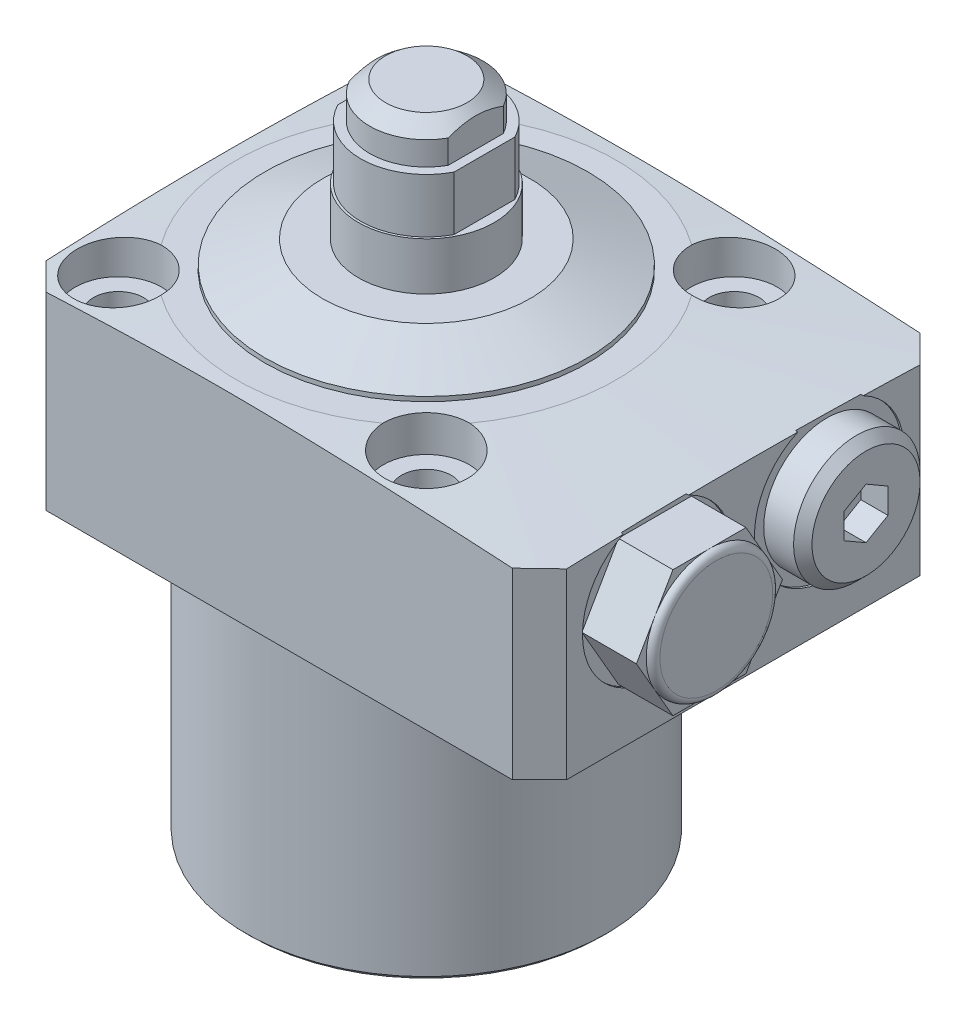
from build123d import *

# Parameters (mm, degrees)
SKETCH2_OUTSIDE_W          = 132.276
SKETCH2_OUTSIDE_H          = 132.276
SKETCH2_OUTSIDE_W_2        = 57.5
SKETCH2_OUTSIDE_H_2        = 45
CUT_EXTRUDE1_DEPTH         = 55
CHAMFER2_SIZE              = 3
CHAMFER1_SIZE              = 1.3714599
CHAMFER1_SIZE2             = 1.754126178
SKETCH5_W                  = 1.79
SKETCH5_H                  = 3.988
CUT_EXTRUDE2_DEPTH         = 23.5
CUT_EXTRUDE2_DEPTH_BACK    = 23.5
SKETCH6_W                  = 1.075
SKETCH6_H                  = 5.98
CUT_EXTRUDE3_DEPTH         = 23.5
CUT_EXTRUDE3_DEPTH_BACK    = 23.5
SKETCH10_R                 = 4.75
CUT_EXTRUDE4_DEPTH         = 4
F_5_5_5_5_DIAMETER_HOLE1_D = 5.5
CIRPATTERN1_COUNT          = 4
CUT_EXTRUDE5_DEPTH         = 3
LPATTERN1_COUNT            = 2
LPATTERN1_PITCH            = 19
SKETCH18_R                 = 1.5
LPATTERN2_COUNT            = 2
LPATTERN2_PITCH            = 19
CHAMFER3_SIZE              = 0.5
FILLET1_R                  = 0.5
BOSS_EXTRUDE1_DEPTH        = 6.78


with BuildPart() as part:
    # Sketch1 → Revolve1 (revolve)
    with BuildSketch(Plane.XY, mode=Mode.PRIVATE) as revolve1_sk:
        Polygon((-19.925, 0), (-50, 0), (-50, 19.472122454), (-21, 21.5), (0, 21.5), (0, -32.5), (-19.925, -32.5), align=None)
    revolve(revolve1_sk.sketch.rotate(Axis((0, 0, 0), (0, -1, 0)), 270), axis=Axis((0, 0, 0), (0, -1, 0)))  # turned: the seam where the file's is

    # Sketch2 outside → Cut-Extrude1 (cut, through all)
    with BuildSketch(Plane(origin=(0, 21.5, 0), x_dir=(1, 0, 0), z_dir=(0, 1, 0))):
        Rectangle(SKETCH2_OUTSIDE_W, SKETCH2_OUTSIDE_H)
        with Locations((6.25, 0)):
            Rectangle(SKETCH2_OUTSIDE_W_2, SKETCH2_OUTSIDE_H_2, mode=Mode.SUBTRACT)
    extrude(amount=-CUT_EXTRUDE1_DEPTH, mode=Mode.SUBTRACT)

    # Chamfer2
    chamfer2_edges = [part.edges().sort_by_distance(p)[0] for p in [
        (-22.5, 10.37170276, -22.5),
        (35, 10.029463905, -22.5),
        (35, 10.029463905, 22.5),
        (-22.5, 10.37170276, 22.5),
    ]]
    chamfer(chamfer2_edges, length=CHAMFER2_SIZE)

    # Sketch4 → Revolve2 (revolve)
    with BuildSketch(Plane.XY, mode=Mode.PRIVATE) as revolve2_sk:
        Polygon((0, 39.75), (-6.25, 39.75), (-6.25, 35.762), (-7.25, 35.762), (-7.25, 29.782), (-7.5, 29.782), (-7.5, 21.5), (0, 21.5), align=None)
    revolve(revolve2_sk.sketch.rotate(Axis((0, 0, 0), (0, 1, 0)), 270), axis=Axis((0, 0, 0), (0, 1, 0)))  # turned: the seam where the file's is

    # Chamfer1
    chamfer1_edges = [part.edges().sort_by_distance(p)[0] for p in [
        (0, 39.75, 6.25),
    ]]
    chamfer1_side = [part.faces().sort_by_distance(p)[0] for p in [
        (0, 37.756, 6.25),
    ]]
    chamfer(chamfer1_edges, length=CHAMFER1_SIZE, length2=CHAMFER1_SIZE2, reference=chamfer1_side[0])

    # Sketch5 → Cut-Extrude2 (cut, two sides)
    with BuildSketch(Plane.XY) as cut_extrude2_sk:
        with Locations((-6.355, 37.756)):
            Rectangle(SKETCH5_W, SKETCH5_H)
        with Locations((6.355, 37.756)):
            Rectangle(SKETCH5_W, SKETCH5_H)
    extrude(amount=CUT_EXTRUDE2_DEPTH, mode=Mode.SUBTRACT)
    extrude(cut_extrude2_sk.sketch, amount=-CUT_EXTRUDE2_DEPTH_BACK, mode=Mode.SUBTRACT)

    # Sketch6 → Cut-Extrude3 (cut, two sides)
    with BuildSketch(Plane.XY) as cut_extrude3_sk:
        with Locations((-6.9625, 32.772)):
            Rectangle(SKETCH6_W, SKETCH6_H)
        with Locations((6.9625, 32.772)):
            Rectangle(SKETCH6_W, SKETCH6_H)
    extrude(amount=CUT_EXTRUDE3_DEPTH, mode=Mode.SUBTRACT)
    extrude(cut_extrude3_sk.sketch, amount=-CUT_EXTRUDE3_DEPTH_BACK, mode=Mode.SUBTRACT)

    # Sketch10 → Cut-Extrude4 (cut)
    with BuildSketch(Plane(origin=(0, 21.5, 0), x_dir=(1, 0, 0), z_dir=(0, 1, 0))):
        with Locations(Location((-17, 17, 0), (0, 0, 269.316686409))):  # turned: the seam where the file's is
            Circle(SKETCH10_R)
    cut_extrude4 = extrude(amount=-CUT_EXTRUDE4_DEPTH, mode=Mode.SUBTRACT)

    # Ø5.5 (5.5) Diameter Hole1 (through all)
    with Locations(Plane(origin=(-17, 17.5, -17), x_dir=(0, 0, 1), z_dir=(0, 1, 0))):
        with Locations((0, 0)):
            f_5_5_5_5_diameter_hole1 = Hole(F_5_5_5_5_DIAMETER_HOLE1_D / 2)

    # CirPattern1: Cut-Extrude4, Ø5.5 (5.5) Diameter Hole1 ×4 about axis
    cirpattern1_axis = Axis((0, 0, 0), (0, 1, 0))
    add([cut_extrude4.rotate(cirpattern1_axis, i * 360 / CIRPATTERN1_COUNT) for i in range(1, CIRPATTERN1_COUNT)], mode=Mode.SUBTRACT)
    add([f_5_5_5_5_diameter_hole1.rotate(cirpattern1_axis, i * 360 / CIRPATTERN1_COUNT) for i in range(1, CIRPATTERN1_COUNT)], mode=Mode.SUBTRACT)

    # Sketch12 → Cut-Revolve2 (revolve, cut)
    with BuildSketch(Plane.XY.offset(-9.5), mode=Mode.PRIVATE) as cut_revolve2_sk:
        Polygon((35, 21.255), (34.75, 21.255), (34.75, 17.953), (34.2166, 17.4196), (24.1836, 17.4196), (21.528036408, 13), (35, 13), align=None)
    cut_revolve2 = revolve(cut_revolve2_sk.sketch.rotate(Axis((17.95729386, 13, -9.5), (1, 0, 0)), 90), axis=Axis((17.95729386, 13, -9.5), (1, 0, 0)), mode=Mode.SUBTRACT)  # turned: the seam where the file's is

    # Sketch13 → Revolve3 (revolve)
    with BuildSketch(Plane.XY.offset(-9.5), mode=Mode.PRIVATE) as revolve3_sk:
        Polygon((34.75, 19.985), (38.045, 19.985), (39.06, 18.97), (39.06, 13), (34.75, 13), align=None)
    revolve(revolve3_sk.sketch.rotate(Axis((10.466346838, 13, -9.5), (1, 0, 0)), 90), axis=Axis((10.466346838, 13, -9.5), (1, 0, 0)))  # turned: the seam where the file's is

    # Sketch14 → Cut-Extrude5 (cut)
    with BuildSketch(Plane(origin=(39.06, 0, 0), x_dir=(0, 0, -1), z_dir=(1, 0, 0))):
        Polygon((11.9255, 11.599636922), (11.9255, 14.400363078), (9.5, 15.800726156), (7.0745, 14.400363078), (7.0745, 11.599636922), (9.5, 10.199273844), align=None)
    cut_extrude5 = extrude(amount=-CUT_EXTRUDE5_DEPTH, mode=Mode.SUBTRACT)

    # Sketch16 → Cut-Revolve4 (revolve, cut)
    with BuildSketch(Plane(origin=(9.5, 0, -9.5), x_dir=(-1, 0, 0), z_dir=(0, 0, -1)), mode=Mode.PRIVATE) as cut_revolve4_sk:
        Polygon((-17.5, 13.502151548), (-20, 12), (-20, 2.875), (-20.625, 2.25), (-22.5, 2.25), (-22.5, 0), (-17.5, 0), align=None)
    cut_revolve4 = revolve(cut_revolve4_sk.sketch.rotate(Axis((27, -1.224048676, -9.5), (0, -1, 0)), 180), axis=Axis((27, -1.224048676, -9.5), (0, -1, 0)), mode=Mode.SUBTRACT)  # turned: the seam where the file's is

    # LPattern1: Cut-Revolve2, Cut-Extrude5, Cut-Revolve4 ×2
    with Locations(*[(0, 0, i * LPATTERN1_PITCH) for i in range(1, LPATTERN1_COUNT)]):
        add(cut_revolve2, mode=Mode.SUBTRACT)
        add(cut_extrude5, mode=Mode.SUBTRACT)
        add(cut_revolve4, mode=Mode.SUBTRACT)

    # Chamfer3
    chamfer3_edges = [part.edges().sort_by_distance(p)[0] for p in [
        (0, -32.5, -19.925),
    ]]
    chamfer(chamfer3_edges, length=CHAMFER3_SIZE)

    # Fillet1
    fillet1_edges = [part.edges().sort_by_distance(p)[0] for p in [
        (0, 0, -19.925),
    ]]
    fillet(fillet1_edges, radius=FILLET1_R)

    # Sketch19 → Revolve5 (revolve)
    with BuildSketch(Plane.XY, mode=Mode.PRIVATE) as revolve5_sk:
        Polygon((7.5, 21.5), (17.82, 21.5), (17.82, 22), (11.473380261, 24.5), (7.5, 24.5), align=None)
    revolve(revolve5_sk.sketch.rotate(Axis((0, 29.782, 0), (0, -1, 0)), 270), axis=Axis((0, 29.782, 0), (0, -1, 0)))  # turned: the seam where the file's is

    # Sketch21 → Boss-Extrude1 (add)
    with BuildSketch(Plane(origin=(34.75, 0, 0), x_dir=(0, 0, -1), z_dir=(1, 0, 0))):
        Polygon((-1.434416739, 13), (-5.46720837, 19.985), (-13.53279163, 19.985), (-17.565583261, 13), (-13.53279163, 6.015), (-5.46720837, 6.015), align=None)
    extrude(amount=BOSS_EXTRUDE1_DEPTH)

    # Sketch22 → Cut-Revolve5 (revolve, cut)
    with BuildSketch(Plane(origin=(0, 0, 9.5), x_dir=(-1, 0, 0), z_dir=(0, 0, -1)), mode=Mode.PRIVATE) as cut_revolve5_sk:
        with BuildLine():
            Line((-41.53, 19.223), (-44.799366723, 19.223))
            Line((-44.799366723, 19.223), (-44.799366723, 22.794476864))
            Line((-44.799366723, 22.794476864), (-40.768, 22.794476864))
            Line((-40.768, 22.794476864), (-40.768, 19.985))
            ThreePointArc((-40.768, 19.985), (-41.306815367, 19.761815367), (-41.53, 19.223))
        make_face()
    revolve(cut_revolve5_sk.sketch.rotate(Axis((17.95729386, 13, 9.5), (-1, 0, 0)), 270), axis=Axis((17.95729386, 13, 9.5), (-1, 0, 0)), mode=Mode.SUBTRACT)  # turned: the seam where the file's is


with BuildPart() as body_2:
    # Sketch18 → Revolve4 (revolve)
    with BuildSketch(Plane(origin=(-9.5, 0, -9.5), x_dir=(1, 0, 0), z_dir=(0, 0, 1))):
        with Locations((33.001, 0.74999)):
            Circle(SKETCH18_R)
    revolve(axis=Axis((27, -2.585671099, -9.5), (0, -1, 0)))


with BuildPart() as lpattern2_1:
    # LPattern2: pattern copy
    add(body_2.part.moved(Location(Vector(0, 0, 1) * (1 * LPATTERN2_PITCH))))


solid = Compound([part.part, body_2.part, lpattern2_1.part])
